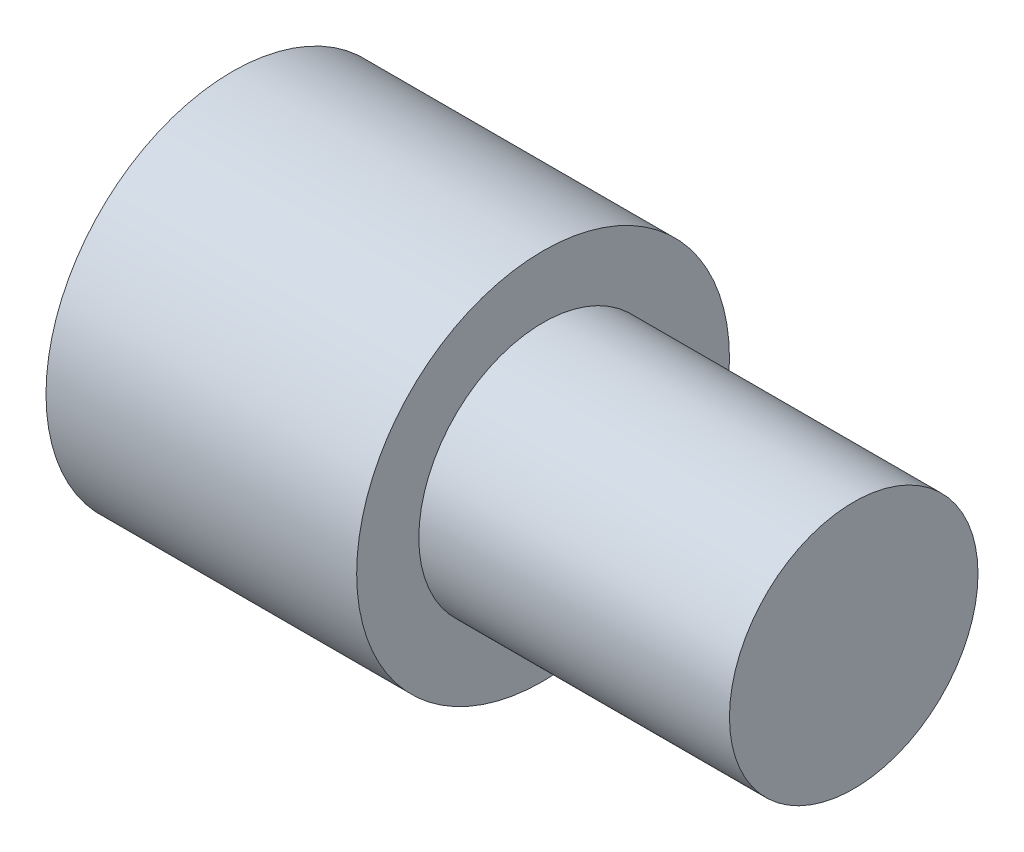
from build123d import *

# Parameters (mm, degrees)
SKETCH1_R           = 4
BOSS_EXTRUDE1_DEPTH = 10
SKETCH2_R           = 6
BOSS_EXTRUDE2_DEPTH = 10


with BuildPart() as part:
    # Sketch1 → Boss-Extrude1 (new body)
    with BuildSketch(Plane(origin=(0, 0, 0), x_dir=(0, 0, -1), z_dir=(1, 0, 0))):
        Circle(SKETCH1_R)
    extrude(amount=BOSS_EXTRUDE1_DEPTH)

    # Sketch2 → Boss-Extrude2 (add)
    with BuildSketch(Plane.ZY):
        Circle(SKETCH2_R)
    extrude(amount=BOSS_EXTRUDE2_DEPTH)


solid = part.part
